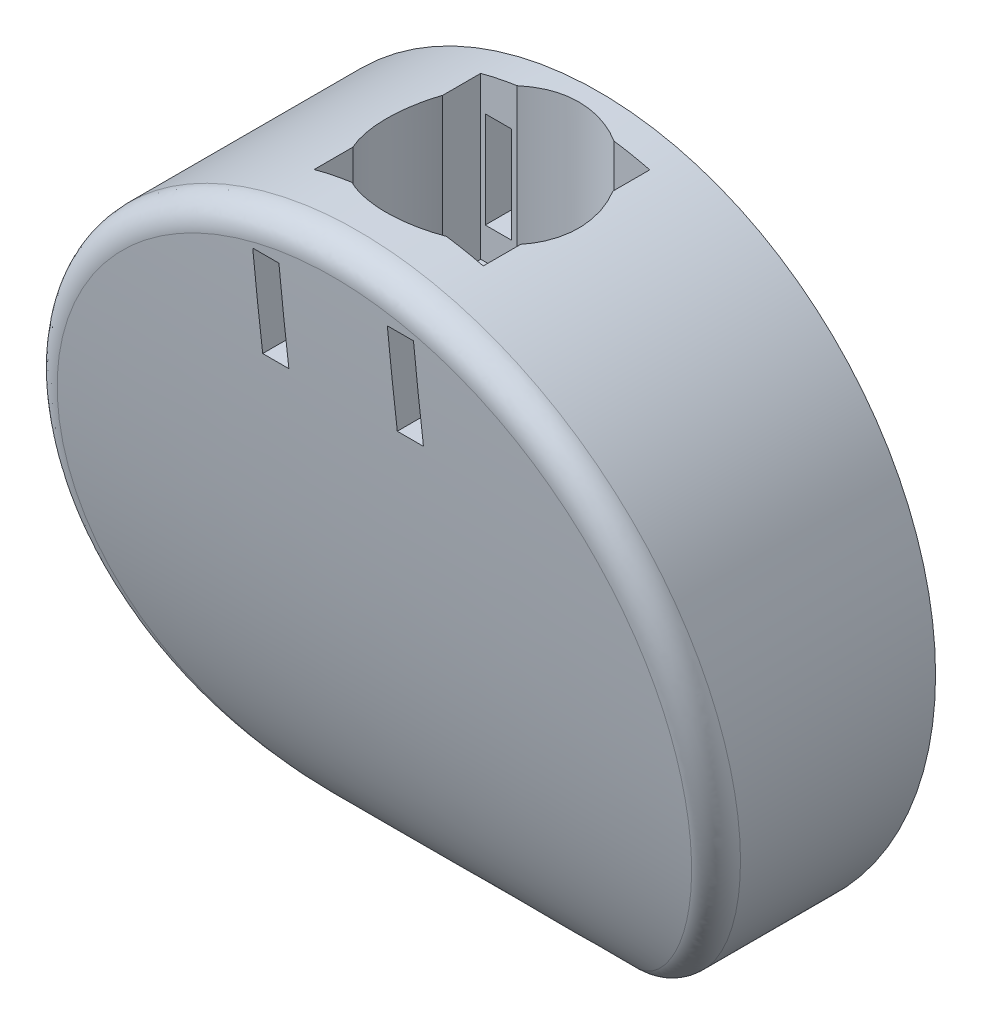
from build123d import *

# Parameters (mm, degrees)
ESQUISSE1_R                  = 67.000000112
BOSS_EXTRU_1_DEPTH           = 53.34
ENL_V_MAT_EXTRU_1_DEPTH      = 110.092762836
ENL_V_MAT_EXTRU_1_DEPTH_BACK = 110.092762836
CONG_1_R                     = 5
ENL_V_MAT_EXTRU_4_DEPTH      = 34.29
ESQUISSE10_W                 = 5.207
ESQUISSE10_H                 = 19.177
ENL_V_MAT_EXTRU_7_DEPTH      = 106.962329583
SYM_TRIE2_COPY_1_SKETCH_W    = 5.207
SYM_TRIE2_COPY_1_SKETCH_H    = 19.177
SYM_TRIE2_COPY_1_DEPTH       = 106.962329583
ESQUISSE7_R                  = 7.62
ENL_V_MAT_EXTRU_8_DEPTH      = 6.35


with BuildPart() as part:
    # Esquisse1 → Boss.-Extru.1 (new body)
    with BuildSketch(Plane.XY):
        with Locations((0.290695021, 0.290695021)):
            Circle(ESQUISSE1_R)
    extrude(amount=BOSS_EXTRU_1_DEPTH)

    # Esquisse4 → Enlèv. mat.-Extru.1 (cut, two sides: drawn at the far end of the back side and taken through both)
    with BuildSketch(Plane(origin=(0, 0, 0), x_dir=(0, 0, -1), z_dir=(1, 0, 0)).offset(-ENL_V_MAT_EXTRU_1_DEPTH_BACK)):
        with BuildLine():
            Line((-0.142164152, -67.127156989), (-53.34, -66.709305091))
            Line((-53.34, -66.709305091), (-53.34, 67.290695133))
            add(Edge.make_bspline(
                [(-53.34, 67.290695133), (-53.314901524, 64.965334409), (-44.651911328, -34.890273822), (-23.160447153, -66.373438876), (-0.142164152, -67.127156989)],
                knots=[0, 0, 0, 0, 0.3629696, 1, 1, 1, 1], degree=3))
        make_face()
    extrude(amount=ENL_V_MAT_EXTRU_1_DEPTH + ENL_V_MAT_EXTRU_1_DEPTH_BACK, mode=Mode.SUBTRACT)

    # Congé1
    cong_1_edges = [part.edges().sort_by_distance(p)[0] for p in [
        (-66.598538996, -3.560329145, 44.401259726),
    ]]
    fillet(cong_1_edges, radius=CONG_1_R)

    # Esquisse6 → Enlèv. mat.-Extru.4 (cut)
    with BuildSketch(Plane(origin=(0, 67.290695133, 0), x_dir=(1, 0, 0), z_dir=(0, 1, 0))):
        with BuildLine():
            Line((-16.910304867, -6.35), (-9.649766032, -6.35))
            ThreePointArc((-9.649766032, -6.35), (-0.019304867, -3.7465), (9.611156298, -6.35))
            Line((9.611156298, -6.35), (16.744695133, -6.35))
            Line((16.744695133, -6.35), (16.744695133, -13.678813462))
            ThreePointArc((16.744695133, -13.678813462), (19.094195133, -22.86), (16.744695133, -32.041186538))
            Line((16.744695133, -32.041186538), (16.744695133, -39.497))
            Line((16.744695133, -39.497), (9.390058196, -39.497))
            ThreePointArc((9.390058196, -39.497), (-0.019304867, -41.9735), (-9.428667929, -39.497))
            Line((-9.428667929, -39.497), (-16.910304867, -39.497))
            Line((-16.910304867, -39.497), (-16.910304867, -31.805389944))
            ThreePointArc((-16.910304867, -31.805389944), (-19.132804867, -22.86), (-16.910304867, -13.914610056))
            Line((-16.910304867, -13.914610056), (-16.910304867, -6.35))
        make_face()
    extrude(amount=-ENL_V_MAT_EXTRU_4_DEPTH, mode=Mode.SUBTRACT)

    # Esquisse10 → Enlèv. mat.-Extru.7 (cut, through all)
    with BuildSketch(Plane.XY.offset(6.35)):
        with Locations((-13.396266032, 48.939195133)):
            Rectangle(ESQUISSE10_W, ESQUISSE10_H)
    enl_v_mat_extru_7 = extrude(amount=-ENL_V_MAT_EXTRU_7_DEPTH, mode=Mode.SUBTRACT)

    # Symétrie1: Enlèv. mat.-Extru.7 across plane
    add(enl_v_mat_extru_7.mirror(Plane(origin=(0, 0, 0), x_dir=(0, 0, 1), z_dir=(1, 0, 0))), mode=Mode.SUBTRACT)

    # Symétrie2: Enlèv. mat.-Extru.7 across plane
    add(enl_v_mat_extru_7.mirror(Plane(origin=(0, 0, 22.861080752), x_dir=(1, 0, 0), z_dir=(0, 0, -1))), mode=Mode.SUBTRACT)

    # Symétrie2 copy 1 sketch → Symétrie2 copy 1 (cut, through all)
    with BuildSketch(Plane(origin=(0, 0, 39.372161503), x_dir=(-1, 0, 0), z_dir=(0, 0, -1))):
        with Locations((-13.396266032, 48.939195133)):
            Rectangle(SYM_TRIE2_COPY_1_SKETCH_W, SYM_TRIE2_COPY_1_SKETCH_H)
    extrude(amount=-SYM_TRIE2_COPY_1_DEPTH, mode=Mode.SUBTRACT)

    # Esquisse7 → Enlèv. mat.-Extru.8 (cut)
    with BuildSketch(Plane(origin=(0, 35.540695133, 0), x_dir=(1, 0, 0), z_dir=(0, 1, 0))):
        with Locations(Location((-0.019304867, -22.86, 0), (0, 0, 270))):
            Circle(ESQUISSE7_R)
    extrude(amount=-ENL_V_MAT_EXTRU_8_DEPTH, mode=Mode.SUBTRACT)


solid = part.part
